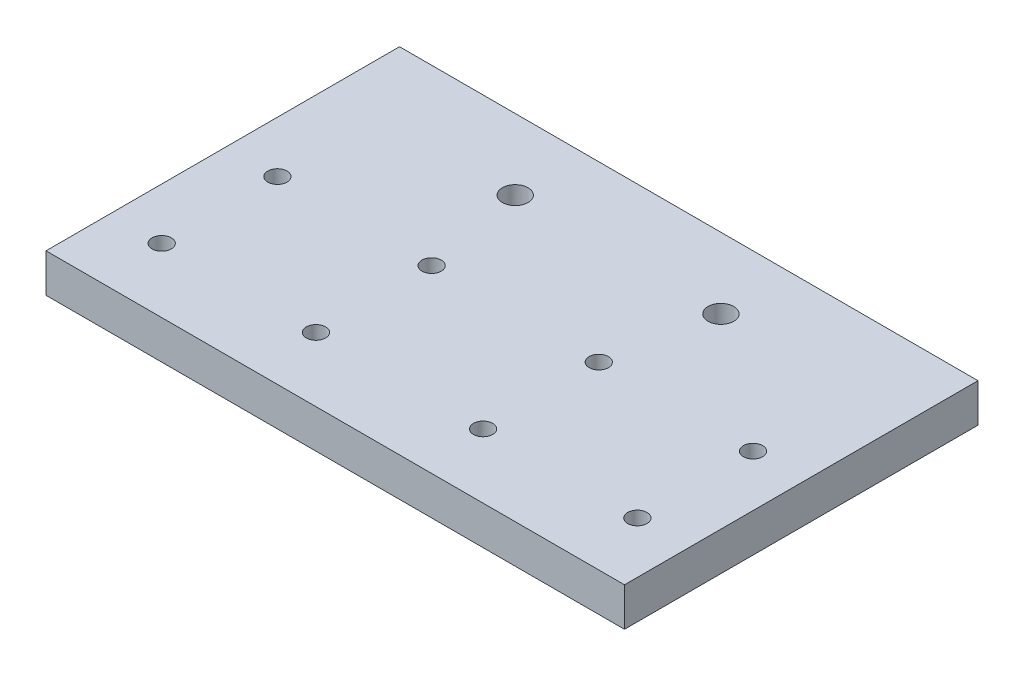
from build123d import *

# Parameters (mm, degrees)
SKETCH1_W           = 90
SKETCH1_H           = 55
SKETCH1_R           = 1.5
BOSS_EXTRUDE1_DEPTH = 6
CUT_EXTRUDE1_REACH  = 8
SKETCH2_R           = 2


with BuildPart() as part:
    # Sketch1 → Boss-Extrude1 (new body)
    with BuildSketch(Plane(origin=(0, 0, 0), x_dir=(1, 0, 0), z_dir=(0, 1, 0))):
        with Locations((0, 2.5)):
            Rectangle(SKETCH1_W, SKETCH1_H)
        with Locations((37, 3)):
            Circle(SKETCH1_R, mode=Mode.SUBTRACT)
        with Locations((13, 3)):
            Circle(SKETCH1_R, mode=Mode.SUBTRACT)
        with Locations((37, -15)):
            Circle(SKETCH1_R, mode=Mode.SUBTRACT)
        with Locations((13, -15)):
            Circle(SKETCH1_R, mode=Mode.SUBTRACT)
        with Locations((-37, -15)):
            Circle(SKETCH1_R, mode=Mode.SUBTRACT)
        with Locations((-37, 3)):
            Circle(SKETCH1_R, mode=Mode.SUBTRACT)
        with Locations((-13, -15)):
            Circle(SKETCH1_R, mode=Mode.SUBTRACT)
        with Locations((-13, 3)):
            Circle(SKETCH1_R, mode=Mode.SUBTRACT)
    extrude(amount=BOSS_EXTRUDE1_DEPTH)

    # Sketch2 → Cut-Extrude1 (cut, up to next)
    with BuildSketch(Plane(origin=(0, 6, 0), x_dir=(1, 0, 0), z_dir=(0, 1, 0)), mode=Mode.PRIVATE) as cut_extrude1_sk1:
        with Locations((16, 19)):
            Circle(SKETCH2_R)
    cut_extrude1_tool1 = extrude(cut_extrude1_sk1.sketch, amount=-CUT_EXTRUDE1_REACH, mode=Mode.PRIVATE) & part.part
    add(cut_extrude1_tool1.solids().sort_by_distance((16, 6, -19))[0], mode=Mode.SUBTRACT)
    # Sketch2 → Cut-Extrude1 (cut, up to next)
    with BuildSketch(Plane(origin=(0, 6, 0), x_dir=(1, 0, 0), z_dir=(0, 1, 0)), mode=Mode.PRIVATE) as cut_extrude1_sk2:
        with Locations((-16, 19)):
            Circle(SKETCH2_R)
    cut_extrude1_tool2 = extrude(cut_extrude1_sk2.sketch, amount=-CUT_EXTRUDE1_REACH, mode=Mode.PRIVATE) & part.part
    add(cut_extrude1_tool2.solids().sort_by_distance((-16, 6, -19))[0], mode=Mode.SUBTRACT)


solid = part.part
